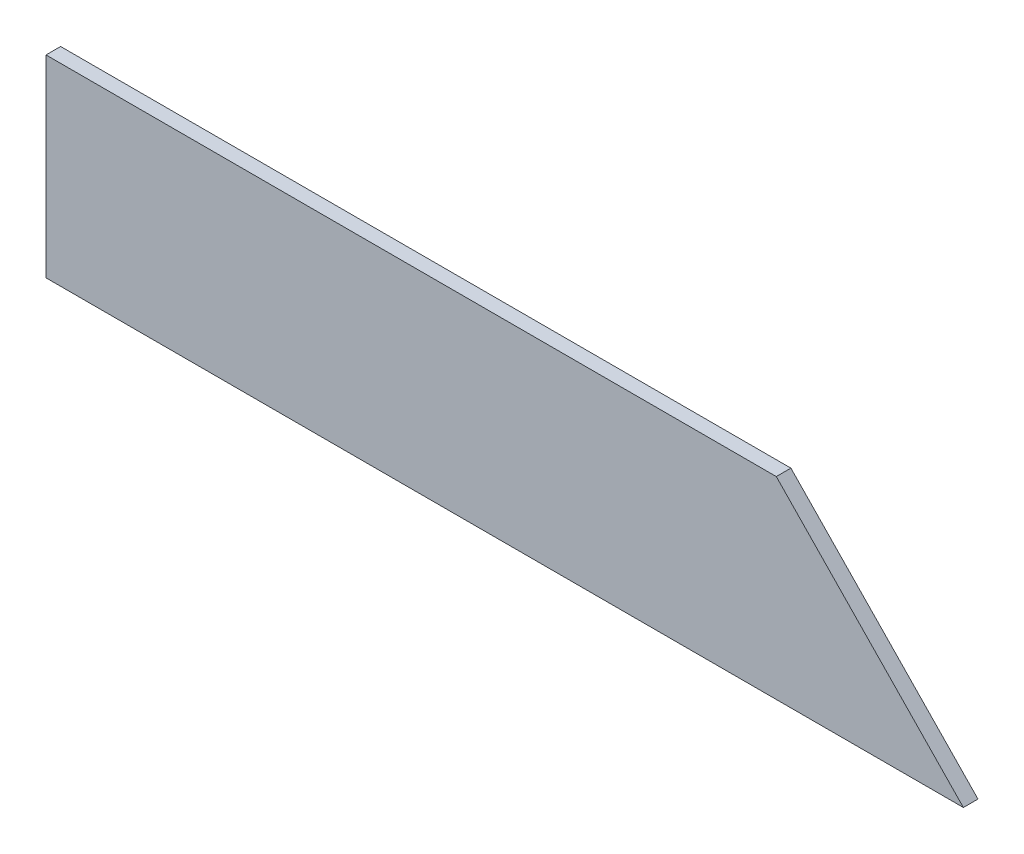
from build123d import *

# Parameters (mm, degrees)
BOSS_EXTRUDE1_DEPTH = 18.25625


with BuildPart() as part:
    # Sketch1 → Boss-Extrude1 (new body)
    with BuildSketch(Plane.XY):
        Polygon((625.390948017, -12.235365854), (391.554980248, 229.064634146), (-521.165051983, 229.064634146), (-521.165051983, -12.235365854), align=None)
    extrude(amount=BOSS_EXTRUDE1_DEPTH)


solid = part.part
